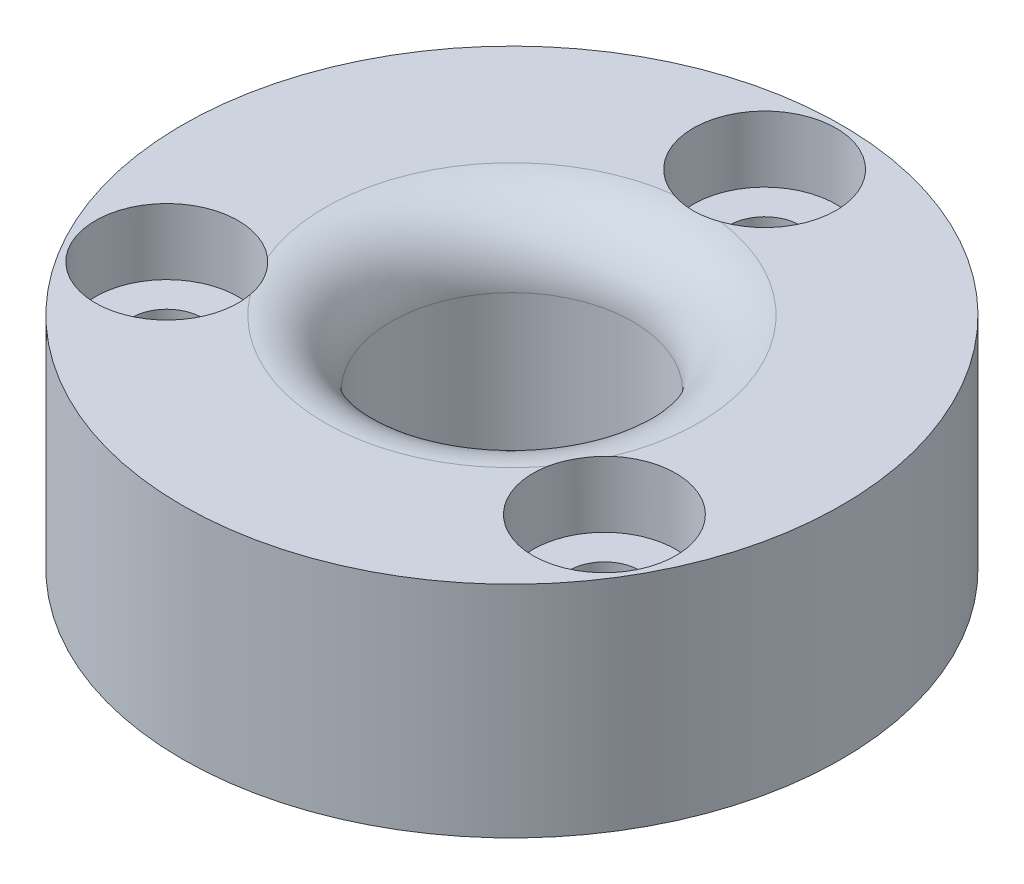
from build123d import *

# Parameters (mm, degrees)
SKETCH1_R                      = 15
SKETCH1_R_2                    = 5.5
BOSS_EXTRUDE1_DEPTH            = 10
FILLET1_R                      = 3
CBORE_FOR_M3_SHCS1_D           = 3.2
CBORE_FOR_M3_SHCS1_CBORE_D     = 6.5
CBORE_FOR_M3_SHCS1_CBORE_DEPTH = 3
CIRPATTERN1_COUNT              = 3


with BuildPart() as part:
    # Sketch1 → Boss-Extrude1 (new body)
    with BuildSketch(Plane(origin=(0, 0, 0), x_dir=(1, 0, 0), z_dir=(0, 1, 0))):
        Circle(SKETCH1_R)
        Circle(SKETCH1_R_2, mode=Mode.SUBTRACT)
    extrude(amount=BOSS_EXTRUDE1_DEPTH)

    # Fillet1
    fillet1_edges = [part.edges().sort_by_distance(p)[0] for p in [
        (-5.5, 10, 0),
    ]]
    fillet(fillet1_edges, radius=FILLET1_R)

    # CBORE for M3 SHCS1 (through all)
    with Locations(Plane(origin=(0, 10, 0), x_dir=(-1, 0, 0), z_dir=(0, 1, 0))):
        with Locations((0, -11.5)):
            cbore_for_m3_shcs1 = CounterBoreHole(CBORE_FOR_M3_SHCS1_D / 2, CBORE_FOR_M3_SHCS1_CBORE_D / 2, CBORE_FOR_M3_SHCS1_CBORE_DEPTH)

    # CirPattern1: CBORE for M3 SHCS1 ×3 about axis
    cirpattern1_axis = Axis((0, 8, 0), (0, -1, 0))
    for i in range(1, CIRPATTERN1_COUNT):
        add(cbore_for_m3_shcs1.rotate(cirpattern1_axis, i * 360 / CIRPATTERN1_COUNT), mode=Mode.SUBTRACT)


solid = part.part
